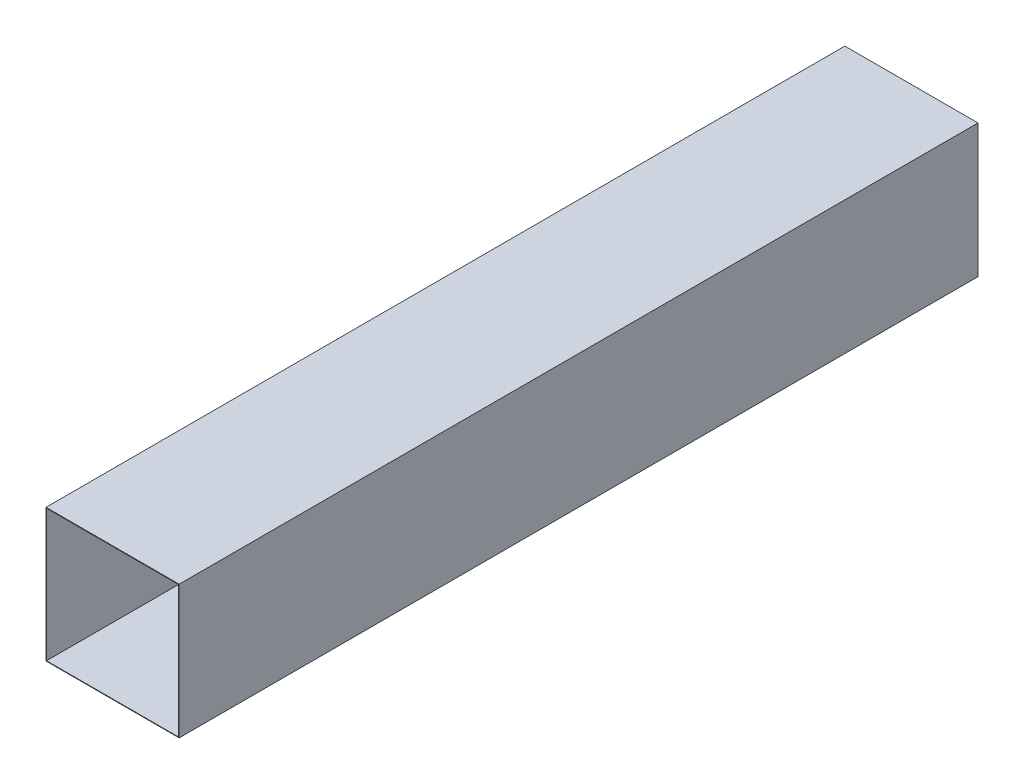
from build123d import *

# Parameters (mm, degrees)
DUCTSKETCH_W    = 500
DUCTSKETCH_H    = 500
DUCTSKETCH_W_2  = 496
DUCTSKETCH_H_2  = 496
EXTRUSION_DEPTH = 3000


with BuildPart() as part:
    # DuctSketch → Extrusion (new body)
    with BuildSketch(Plane.XY):
        Rectangle(DUCTSKETCH_W, DUCTSKETCH_H)
        Rectangle(DUCTSKETCH_W_2, DUCTSKETCH_H_2, mode=Mode.SUBTRACT)
    extrude(amount=EXTRUSION_DEPTH)


solid = part.part
